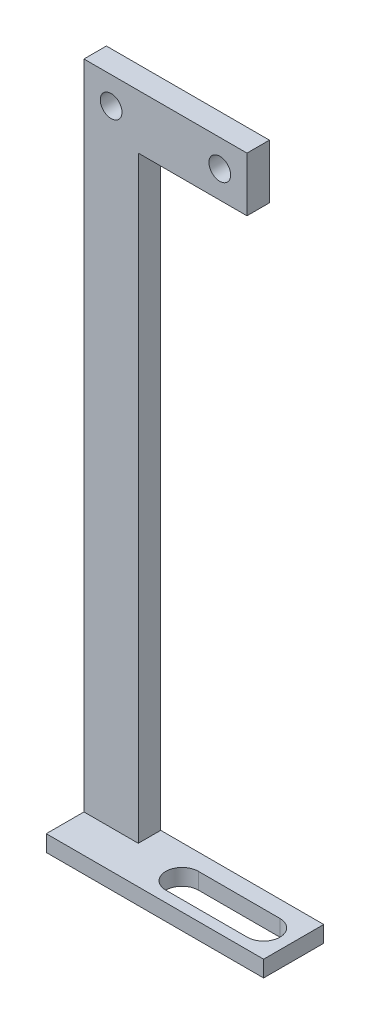
from build123d import *

# Parameters (mm, degrees)
EXTRUDE_1_DEPTH      = 3
SKETCH_4_W           = 15
SKETCH_4_H           = 10
EXTRUDE_3_DEPTH      = 3
SKETCH_5_W           = 10
SKETCH_5_H           = 4.129403984
EXTRUDE_4_DEPTH      = 120
EXTRUDE_4_DEPTH_BACK = 3
SKETCH_6_R           = 2
CUT_EXTRUDE_2_DEPTH  = 5.129403983
SKETCH_7_W           = 1.064701992
SKETCH_7_H           = 3
EXTRUDE_5_DEPTH      = 30
SKETCH_8_W           = 4.129403984
SKETCH_8_H           = 10
EXTRUDE_6_DEPTH      = 20
SKETCH_9_R           = 2
CUT_EXTRUDE_3_DEPTH  = 5.129403983


with BuildPart() as part:
    # 草图1 → 凸台-拉伸1 (new body)
    with BuildSketch(Plane(origin=(0, 0, 0), x_dir=(1, 0, 0), z_dir=(0, 1, 0))):
        with BuildLine():
            Line((25, 0), (0, 0))
            Line((0, 0), (0, -5))
            Line((0, -5), (2, -5))
            ThreePointArc((2, -5), (2.878679656, -2.878679656), (5, -2))
            Line((5, -2), (20, -2))
            ThreePointArc((20, -2), (22.121320344, -2.878679656), (23, -5))
            Line((23, -5), (25, -5))
            Line((25, -5), (25, 0))
        make_face()
        with BuildLine():
            Line((2, -5), (0, -5))
            Line((0, -5), (0, -10))
            Line((0, -10), (25, -10))
            Line((25, -10), (25, -5))
            Line((25, -5), (23, -5))
            ThreePointArc((23, -5), (22.121320344, -7.121320344), (20, -8))
            Line((20, -8), (5, -8))
            ThreePointArc((5, -8), (2.878679656, -7.121320344), (2, -5))
        make_face()
    extrude(amount=EXTRUDE_1_DEPTH)

    # 草图4 → 凸台-拉伸3 (add)
    with BuildSketch(Plane(origin=(0, 3, 0), x_dir=(1, 0, 0), z_dir=(0, 1, 0))):
        with Locations((-7.5, -5)):
            Rectangle(SKETCH_4_W, SKETCH_4_H)
    extrude(amount=-EXTRUDE_3_DEPTH)

    # 草图5 → 凸台-拉伸4 (add, two sides)
    with BuildSketch(Plane(origin=(0, 3, 0), x_dir=(1, 0, 0), z_dir=(0, 1, 0))) as extrude_4_sk:
        with Locations((-10, -1)):
            Rectangle(SKETCH_5_W, SKETCH_5_H)
    extrude(amount=EXTRUDE_4_DEPTH)
    extrude(extrude_4_sk.sketch, amount=-EXTRUDE_4_DEPTH_BACK)

    # 草图6 → 切除-拉伸2 (cut, through all)
    with BuildSketch(Plane.XY.offset(3.064701992)):
        with Locations((-10, 118)):
            Circle(SKETCH_6_R)
    extrude(amount=-CUT_EXTRUDE_2_DEPTH, mode=Mode.SUBTRACT)

    # 草图7 → 凸台-拉伸5 (add, through all)
    with BuildSketch(Plane(origin=(-5, 0, 0), x_dir=(0, 0, -1), z_dir=(1, 0, 0))):
        with Locations((0.532350996, 1.5)):
            Rectangle(SKETCH_7_W, SKETCH_7_H)
    extrude(amount=EXTRUDE_5_DEPTH)

    # 草图8 → 凸台-拉伸6 (add)
    with BuildSketch(Plane(origin=(-5, 0, 0), x_dir=(0, 0, -1), z_dir=(1, 0, 0))):
        with Locations((-1, 118)):
            Rectangle(SKETCH_8_W, SKETCH_8_H)
    extrude(amount=EXTRUDE_6_DEPTH)

    # 草图9 → 切除-拉伸3 (cut, through all)
    with BuildSketch(Plane.XY.offset(3.064701992)):
        with Locations((10, 118)):
            Circle(SKETCH_9_R)
    extrude(amount=-CUT_EXTRUDE_3_DEPTH, mode=Mode.SUBTRACT)


solid = part.part
